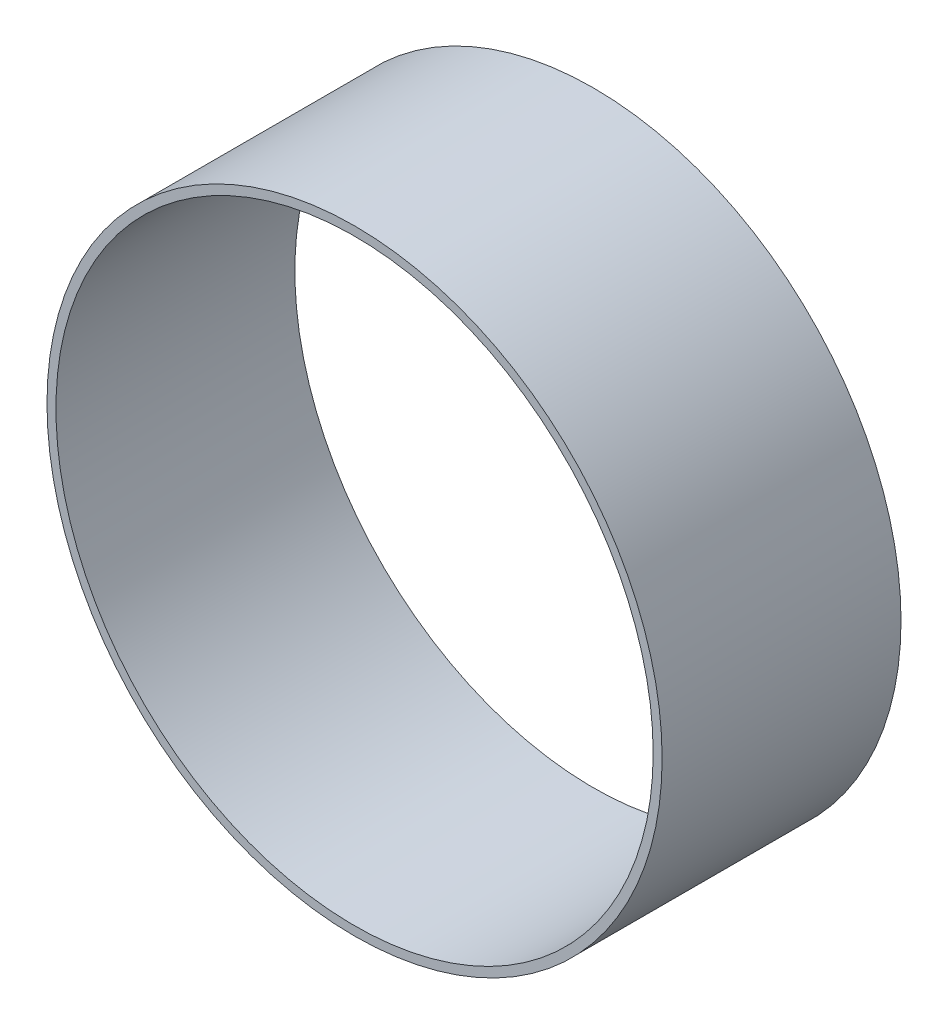
from build123d import *

# Parameters (mm, degrees)
SKETCH1_R           = 65.405
SKETCH1_R_2         = 63.5
BOSS_EXTRUDE1_DEPTH = 25.4


with BuildPart() as part:
    # Sketch1 → Boss-Extrude1 (new body, symmetric)
    with BuildSketch(Plane.XY):
        Circle(SKETCH1_R)
        Circle(SKETCH1_R_2, mode=Mode.SUBTRACT)
    extrude(amount=BOSS_EXTRUDE1_DEPTH, both=True)


solid = part.part
